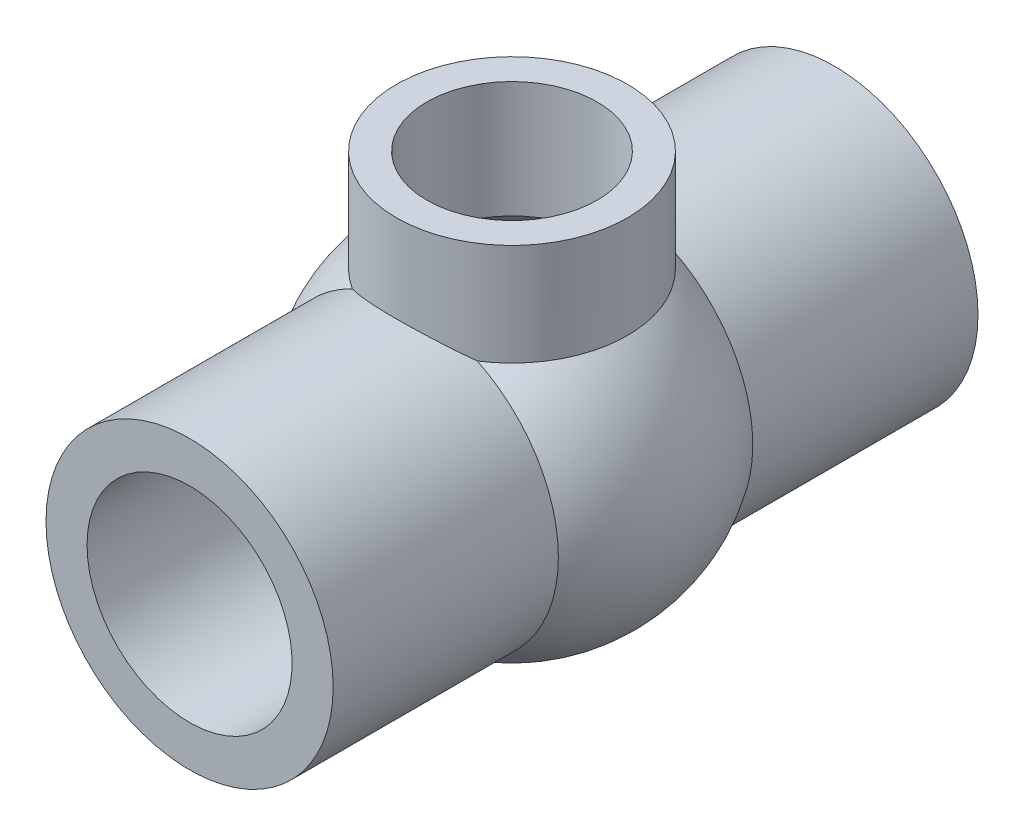
from build123d import *

# Parameters (mm, degrees)
SCALE1_SCALE = 0.623


with BuildPart() as part:
    # Sketch2 → RevolveBody (revolve)
    with BuildSketch(Plane(origin=(0, 0, 0), x_dir=(0, 0, -1), z_dir=(1, 0, 0))):
        with BuildLine():
            Line((53, 23.6), (15.977797095, 23.6))
            ThreePointArc((15.977797095, 23.6), (0, 28.5), (-15.977797095, 23.6))
            Line((-15.977797095, 23.6), (-53, 23.6))
            Line((-53, 23.6), (-53, 0))
            Line((-53, 0), (53, 0))
            Line((53, 0), (53, 23.6))
        make_face()
    revolve(axis=Axis((0, 0, 97.71293904), (0, 0, -1)))

    # Sketch3 → RevStem (revolve)
    with BuildSketch(Plane(origin=(0, 0, 0), x_dir=(0, 0, -1), z_dir=(1, 0, 0))):
        with BuildLine():
            Line((19, 38), (19, 21.242645786))
            ThreePointArc((19, 21.242645786), (10.169429559, 26.62391223), (0, 28.5))
            Line((0, 28.5), (0, 38))
            Line((0, 38), (19, 38))
        make_face()
    revolve(axis=Axis((0, 38, 0), (0, -1, 0)))

    # Sketch4 → CoreBody (revolve, cut)
    with BuildSketch(Plane(origin=(0, 0, 0), x_dir=(0, 0, -1), z_dir=(1, 0, 0))):
        Polygon((53, 16.85), (53, 0), (-53, 0), (-53, 16.85), (-25, 16.85), (-25, 12.5), (25, 12.5), (25, 16.85), align=None)
    revolve(axis=Axis((0, 0, -53), (0, 0, 1)), mode=Mode.SUBTRACT)

    # Sketch5 → CoreStem (revolve, cut)
    with BuildSketch(Plane(origin=(0, 0, 0), x_dir=(0, 0, -1), z_dir=(1, 0, 0))):
        with BuildLine():
            Line((14, 38), (0, 38))
            Line((0, 38), (0, -23.5))
            ThreePointArc((0, -23.5), (22.313704008, -7.37215121), (14, 18.874586088))
            Line((14, 18.874586088), (14, 38))
        make_face()
    revolve(axis=Axis((0, 58.20350065, 0), (0, -1, 0)), mode=Mode.SUBTRACT)


with BuildPart() as part_1:
    # Scale1: scaled about (-8.85e-07, 1.551247427, 4.25e-06)
    add(part.part.scale(SCALE1_SCALE).moved(Location((-3.34e-07, 0.58482028, 1.602e-06))))


solid = part_1.part
